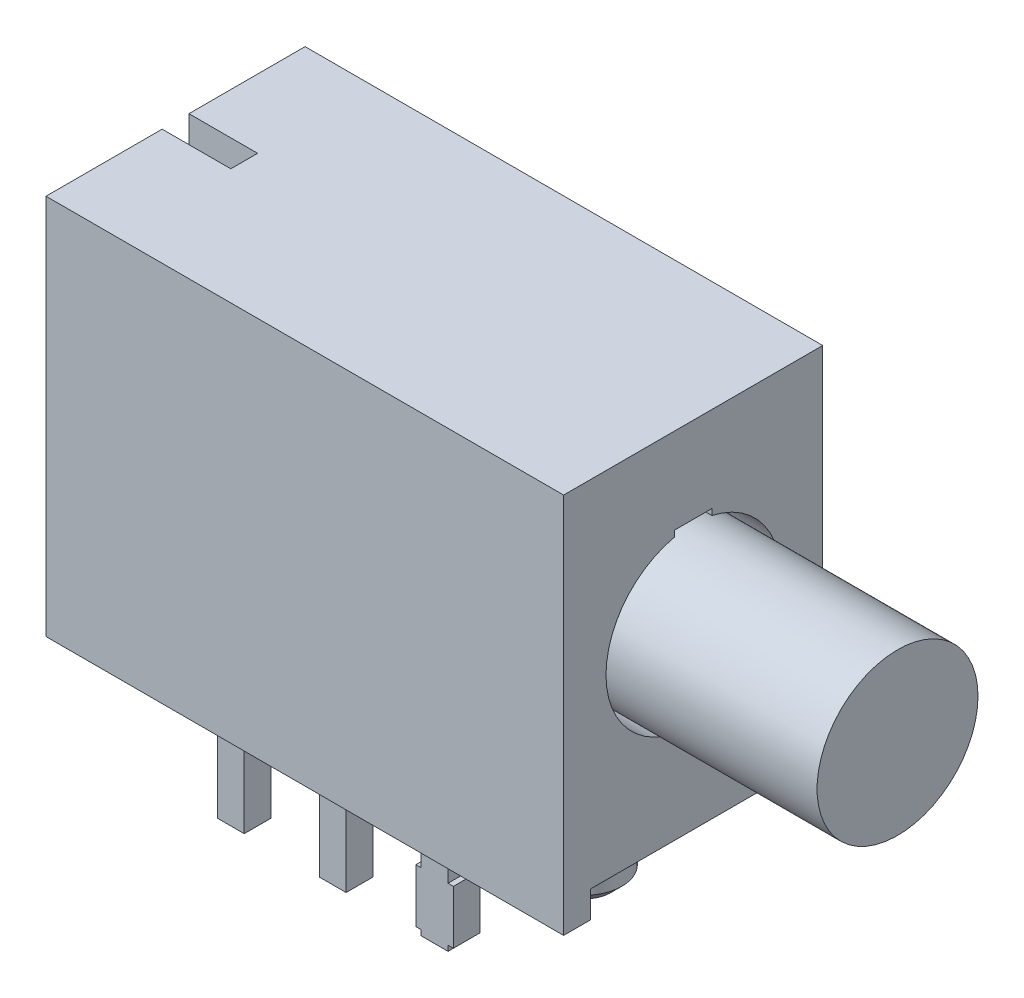
from build123d import *

# Parameters (mm, degrees)
SKETCH1_W          = 9.65
SKETCH1_H          = 7.11
EXTRUDE1_DEPTH     = 4.83
SKETCH3_W          = 3.83
SKETCH3_H          = 0.5
CUT_EXTRUDE1_DEPTH = 10.65
SKETCH3_3_R        = 1.5
EXTRUDE2_DEPTH     = 3.81
CUT_EXTRUDE2_DEPTH = 2.3
CUT_EXTRUDE3_DEPTH = 2.3
SKETCH4_W          = 0.5
SKETCH4_H          = 0.5
EXTRUDE3_DEPTH     = 4
SKETCH5_W          = 0.1
SKETCH5_H          = 1
SKETCH5_W_2        = 0.5
EXTRUDE4_DEPTH     = 0.5
SKETCH4_3_R        = 0.7
EXTRUDE5_DEPTH     = 1.78
CHAMFER1_SIZE      = 0.2
SKETCH3_8_R        = 1.625
SKETCH3_8_R_2      = 1.5
CUT_EXTRUDE4_DEPTH = 2.3
SKETCH7_W          = 1.4
SKETCH7_H          = 0.5
CUT_EXTRUDE5_DEPTH = 3.31
SKETCH7_5_W        = 1.3
SKETCH7_5_H        = 0.5
CUT_EXTRUDE6_DEPTH = 2.5
SKETCH8_W          = 1.03
SKETCH8_H          = 0.5
CUT_EXTRUDE7_DEPTH = 11.61
SKETCH8_5_W        = 0.25
SKETCH8_5_H        = 0.5
CUT_EXTRUDE8_DEPTH = 0.25
SKETCH9_W          = 0.026582278
SKETCH9_H          = 0.025316455
SKETCH9_H_2        = 0.025316456
CUT_EXTRUDE9_DEPTH = 0.01


with BuildPart() as part:
    # Sketch1 → Extrude1 (new body)
    with BuildSketch(Plane.XY):
        with Locations((4.825, 3.555)):
            Rectangle(SKETCH1_W, SKETCH1_H)
    extrude(amount=-EXTRUDE1_DEPTH)

    # Sketch3 → Cut-Extrude1 (cut, through all)
    with BuildSketch(Plane(origin=(9.65, 0, 0), x_dir=(0, 0, -1), z_dir=(1, 0, 0))):
        with Locations((2.415, 0.25)):
            Rectangle(SKETCH3_W, SKETCH3_H)
    extrude(amount=-CUT_EXTRUDE1_DEPTH, mode=Mode.SUBTRACT)

    # Sketch3_3 → Extrude2 (add)
    with BuildSketch(Plane(origin=(9.65, 0, 0), x_dir=(0, 0, -1), z_dir=(1, 0, 0))):
        with Locations((2.415, 3.81)):
            Circle(SKETCH3_3_R)
    extrude(amount=EXTRUDE2_DEPTH)

    # Sketch3_6 → Cut-Extrude2 (cut)
    with BuildSketch(Plane(origin=(9.65, 0, 0), x_dir=(0, 0, -1), z_dir=(1, 0, 0))):
        with BuildLine():
            Line((2.764999871, 5.51), (2.064999871, 5.51))
            Line((2.064999871, 5.51), (2.064999871, 5.396860079))
            ThreePointArc((2.064999871, 5.396860079), (2.414999868, 5.435), (2.764999871, 5.396860136))
            Line((2.764999871, 5.396860136), (2.764999871, 5.51))
        make_face()
    extrude(amount=-CUT_EXTRUDE2_DEPTH, mode=Mode.SUBTRACT)

    # Sketch3_7 → Cut-Extrude3 (cut)
    with BuildSketch(Plane(origin=(9.65, 0, 0), x_dir=(0, 0, -1), z_dir=(1, 0, 0))):
        with BuildLine():
            ThreePointArc((2.764999871, 2.223139864), (2.414999868, 2.185), (2.064999871, 2.223139921))
            Line((2.064999871, 2.223139921), (2.064999871, 2.11))
            Line((2.064999871, 2.11), (2.764999871, 2.11))
            Line((2.764999871, 2.11), (2.764999871, 2.223139864))
        make_face()
    extrude(amount=-CUT_EXTRUDE3_DEPTH, mode=Mode.SUBTRACT)

    # Sketch4 → Extrude3 (add)
    with BuildSketch(Plane.XZ.offset(-0.5)):
        with Locations((3.18, -2.415)):
            Rectangle(SKETCH4_W, SKETCH4_H)
        with Locations((5.08, -2.415)):
            Rectangle(SKETCH4_W, SKETCH4_H)
        with Locations((1.28, -2.415)):
            Rectangle(SKETCH4_W, SKETCH4_H)
    extrude(amount=EXTRUDE3_DEPTH)

    # Sketch5 → Extrude4 (add)
    with BuildSketch(Plane.XY.offset(-2.165)):
        with Locations((5.38, -2.9)):
            Rectangle(SKETCH5_W, SKETCH5_H)
        with Locations((5.08, -2.9)):
            Rectangle(SKETCH5_W_2, SKETCH5_H)
        with Locations((4.78, -2.9)):
            Rectangle(SKETCH5_W, SKETCH5_H)
    extrude(amount=-EXTRUDE4_DEPTH)

    # Sketch4_3 → Extrude5 (add)
    with BuildSketch(Plane.XZ.offset(-0.5)):
        with Locations(Location((7.62, -2.415, 0), (0, 0, 270))):  # turned: the seam where the file's is
            Circle(SKETCH4_3_R)
    extrude(amount=EXTRUDE5_DEPTH)

    # Chamfer1
    chamfer1_edges = [part.edges().sort_by_distance(p)[0] for p in [
        (7.62, -1.28, -1.715),
    ]]
    chamfer(chamfer1_edges, length=CHAMFER1_SIZE)

    # Sketch3_8 → Cut-Extrude4 (cut)
    with BuildSketch(Plane(origin=(9.65, 0, 0), x_dir=(0, 0, -1), z_dir=(1, 0, 0))):
        with Locations((2.415, 3.81)):
            Circle(SKETCH3_8_R)
        with Locations((2.415, 3.81)):
            Circle(SKETCH3_8_R_2, mode=Mode.SUBTRACT)
    extrude(amount=-CUT_EXTRUDE4_DEPTH, mode=Mode.SUBTRACT)

    # Sketch7 → Cut-Extrude5 (cut)
    with BuildSketch(Plane.XZ.offset(-0.5)):
        with Locations((2.23, -2.415)):
            Rectangle(SKETCH7_W, SKETCH7_H)
    extrude(amount=-CUT_EXTRUDE5_DEPTH, mode=Mode.SUBTRACT)

    # Sketch7_5 → Cut-Extrude6 (cut)
    with BuildSketch(Plane.XZ.offset(-0.5)):
        with Locations((4.08, -2.415)):
            Rectangle(SKETCH7_5_W, SKETCH7_5_H)
    extrude(amount=-CUT_EXTRUDE6_DEPTH, mode=Mode.SUBTRACT)

    # Sketch8 → Cut-Extrude7 (cut, through all)
    with BuildSketch(Plane(origin=(0, 7.11, 0), x_dir=(-1, 0, 0), z_dir=(0, 1, 0))):
        with Locations((-0.515, -2.415)):
            Rectangle(SKETCH8_W, SKETCH8_H)
    extrude(amount=-CUT_EXTRUDE7_DEPTH, mode=Mode.SUBTRACT)

    # Sketch8_5 → Cut-Extrude8 (cut)
    with BuildSketch(Plane(origin=(0, 7.11, 0), x_dir=(-1, 0, 0), z_dir=(0, 1, 0))):
        with Locations((-1.155, -2.415)):
            Rectangle(SKETCH8_5_W, SKETCH8_5_H)
    extrude(amount=-CUT_EXTRUDE8_DEPTH, mode=Mode.SUBTRACT)

    # Sketch9 → Cut-Extrude9 (cut)
    with BuildSketch(Plane.XZ.offset(-0.5)):
        Polygon((5.37653482, -1.857436776), (5.301851276, -1.833979497), (5.301851276, -1.809236618), (5.35218751, -1.792820478), (5.301851276, -1.777294371), (5.301851276, -1.751562567), (5.37653482, -1.728322852), (5.37653482, -1.753500858), (5.325051434, -1.76649532), (5.37653482, -1.782911459), (5.37653482, -1.804410668), (5.325051434, -1.820727915), (5.37653482, -1.833544371), align=None)
        Polygon((5.37653482, -1.991613991), (5.301851276, -1.968156713), (5.301851276, -1.943413833), (5.35218751, -1.926997694), (5.301851276, -1.911471586), (5.301851276, -1.885739782), (5.37653482, -1.862500067), (5.37653482, -1.887678073), (5.325051434, -1.900672535), (5.37653482, -1.917088675), (5.37653482, -1.938587883), (5.325051434, -1.95490513), (5.37653482, -1.967721586), align=None)
        Polygon((5.37653482, -2.125791206), (5.301851276, -2.102333928), (5.301851276, -2.077591048), (5.35218751, -2.061174909), (5.301851276, -2.045648801), (5.301851276, -2.019916997), (5.37653482, -1.996677282), (5.37653482, -2.021855288), (5.325051434, -2.03484975), (5.37653482, -2.05126589), (5.37653482, -2.072765099), (5.325051434, -2.089082345), (5.37653482, -2.101898801), align=None)
        with Locations((5.315142415, -2.153639307)):
            Rectangle(SKETCH9_W, SKETCH9_H)
        with BuildLine():
            add(Edge.make_bspline(
                [(5.333022162, -2.270095004), (5.331800028, -2.270058505), (5.329400166, -2.269986835), (5.325892478, -2.269377249), (5.322568174, -2.268383281), (5.319404028, -2.267010942), (5.31643454, -2.265217486), (5.313631648, -2.263034215), (5.311027104, -2.260445332), (5.308590729, -2.257498528), (5.306408618, -2.254201585), (5.304502585, -2.250603871), (5.302907914, -2.246723844), (5.301568848, -2.242575633), (5.300580415, -2.238129086), (5.299856427, -2.233411588), (5.29938311, -2.22841816), (5.299341142, -2.224994583), (5.29931963, -2.223239782)],
                knots=[0, 0, 0, 0, 0.907312236, 1.78165839, 2.635367075, 3.479697475, 4.336364812, 5.205276731, 6.11257575, 7.058770404, 8.040786331, 9.044147278, 10.078219212, 11.153049307, 12.278104542, 13.457648573, 14.696882856, 16, 16, 16, 16], degree=3))
            add(Edge.make_bspline(
                [(5.29931963, -2.223239782), (5.299343702, -2.221221527), (5.299390327, -2.217312344), (5.299818926, -2.211648819), (5.300465065, -2.206380782), (5.301431607, -2.201485067), (5.302632372, -2.196880468), (5.303923664, -2.1924472), (5.305388079, -2.188165889), (5.306488237, -2.185392799), (5.307033238, -2.184019054)],
                knots=[0, 0, 0, 0, 1.203215828, 2.33052265, 3.384689099, 4.366106119, 5.303329643, 6.221311756, 7.118865988, 8, 8, 8, 8], degree=3))
            Line((5.307033238, -2.184019054), (5.3309652, -2.184019054))
            Line((5.3309652, -2.184019054), (5.3309652, -2.186867156))
            add(Edge.make_bspline(
                [(5.3309652, -2.186867156), (5.329883745, -2.18823247), (5.327727184, -2.190955082), (5.324964579, -2.195388315), (5.322562416, -2.200035961), (5.320588414, -2.204881432), (5.31900209, -2.209778276), (5.317908563, -2.214653654), (5.317161214, -2.219419242), (5.317080707, -2.222577811), (5.317041149, -2.224129814)],
                knots=[0, 0, 0, 0, 1.030622468, 2.055194264, 3.087043286, 4.125157485, 5.149848264, 6.130935704, 7.081611712, 8, 8, 8, 8], degree=3))
            add(Edge.make_bspline(
                [(5.317041149, -2.224129814), (5.317042044, -2.224558592), (5.317043959, -2.225476574), (5.317172802, -2.226944611), (5.317265965, -2.22860321), (5.317475183, -2.230382077), (5.317693766, -2.232172894), (5.318074086, -2.233827554), (5.318435925, -2.235331193), (5.318804103, -2.236237675), (5.318979441, -2.236669371)],
                knots=[0, 0, 0, 0, 0.806378557, 1.726393851, 2.771014456, 3.931269413, 5.096090628, 6.161710732, 7.124547685, 8, 8, 8, 8], degree=3))
            add(Edge.make_bspline(
                [(5.318979441, -2.236669371), (5.319207264, -2.237149158), (5.319654986, -2.238092041), (5.320472593, -2.23938696), (5.321343895, -2.240569633), (5.322309314, -2.241631093), (5.323487223, -2.24248136), (5.324888079, -2.243109561), (5.326538379, -2.243452655), (5.32771339, -2.243491949), (5.328334662, -2.243512725)],
                knots=[0, 0, 0, 0, 1.024407818, 2.013179384, 2.949802342, 3.859052226, 4.77034807, 5.732977883, 6.801339628, 8, 8, 8, 8], degree=3))
            add(Edge.make_bspline(
                [(5.328334662, -2.243512725), (5.328880558, -2.243481283), (5.329953951, -2.24341946), (5.331481947, -2.242837668), (5.332903824, -2.24195477), (5.334164539, -2.240667748), (5.335321977, -2.239073671), (5.336292274, -2.237117934), (5.337172348, -2.234864955), (5.337589617, -2.233220496), (5.337808554, -2.232357662)],
                knots=[0, 0, 0, 0, 0.825212765, 1.622611382, 2.449701629, 3.348069183, 4.336544339, 5.428209675, 6.6506027, 8, 8, 8, 8], degree=3))
            add(Edge.make_bspline(
                [(5.337808554, -2.232357662), (5.338256295, -2.230388935), (5.339173485, -2.226356027), (5.340320592, -2.220207918), (5.341586665, -2.21407769), (5.342796206, -2.210118979), (5.343386086, -2.208188358)],
                knots=[0, 0, 0, 0, 0.976104583, 1.999535498, 3.024395274, 4, 4, 4, 4], degree=3))
            add(Edge.make_bspline(
                [(5.343386086, -2.208188358), (5.343739079, -2.207149842), (5.344426212, -2.205128274), (5.345587837, -2.20223673), (5.346857789, -2.199575617), (5.34821292, -2.197135507), (5.349686918, -2.194936185), (5.351220308, -2.192940995), (5.352874145, -2.191197469), (5.354606065, -2.189649785), (5.356458067, -2.188326471), (5.358402204, -2.187171721), (5.360462669, -2.186196085), (5.362623958, -2.185387202), (5.364902826, -2.184770129), (5.3672797, -2.184348873), (5.36976306, -2.184050484), (5.371457413, -2.184029674), (5.372322004, -2.184019054)],
                knots=[0, 0, 0, 0, 1.287286806, 2.505824366, 3.654938963, 4.74627059, 5.778586806, 6.75996495, 7.696030012, 8.595059759, 9.482019644, 10.363222407, 11.245851011, 12.154256429, 13.068444161, 14.012503255, 14.985824751, 16, 16, 16, 16], degree=3))
            add(Edge.make_bspline(
                [(5.372322004, -2.184019054), (5.373478149, -2.184056356), (5.375753421, -2.184129766), (5.379082465, -2.184731194), (5.382231202, -2.185757784), (5.385234665, -2.187143848), (5.388047751, -2.188972476), (5.390726298, -2.19115727), (5.39319789, -2.193781318), (5.395498223, -2.196758439), (5.397577622, -2.200045824), (5.399408178, -2.203584807), (5.40094483, -2.207354096), (5.402218724, -2.211339643), (5.403173395, -2.215558112), (5.403892326, -2.219995345), (5.404305508, -2.224669133), (5.404356758, -2.227860555), (5.404382922, -2.229489782)],
                knots=[0, 0, 0, 0, 0.894990994, 1.761326291, 2.609044902, 3.454222546, 4.315366365, 5.200560057, 6.125081389, 7.100429509, 8.110379559, 9.133447974, 10.182136699, 11.259192205, 12.370181258, 13.528580438, 14.738335141, 16, 16, 16, 16], degree=3))
            add(Edge.make_bspline(
                [(5.404382922, -2.229489782), (5.40436073, -2.231158469), (5.404316385, -2.234493014), (5.403938407, -2.239474456), (5.403383179, -2.244434958), (5.402541473, -2.249298789), (5.401565056, -2.253989344), (5.400469261, -2.25840258), (5.399231296, -2.26248204), (5.398276951, -2.265055704), (5.397816466, -2.266297535)],
                knots=[0, 0, 0, 0, 1.065403572, 2.129000689, 3.188532477, 4.251604565, 5.279552602, 6.247508681, 7.154397237, 8, 8, 8, 8], degree=3))
            Line((5.397816466, -2.266297535), (5.375268998, -2.266297535))
            Line((5.375268998, -2.266297535), (5.375268998, -2.263469213))
            add(Edge.make_bspline(
                [(5.375268998, -2.263469213), (5.376069344, -2.262396308), (5.377706074, -2.260202189), (5.379789746, -2.256542553), (5.381747612, -2.252584317), (5.383431771, -2.248305486), (5.384891252, -2.243846459), (5.385910418, -2.2392635), (5.386552228, -2.234637337), (5.386625003, -2.231535626), (5.386661403, -2.229984244)],
                knots=[0, 0, 0, 0, 0.892283326, 1.824742884, 2.804416662, 3.836872171, 4.8899239, 5.931447339, 6.965372909, 8, 8, 8, 8], degree=3))
            add(Edge.make_bspline(
                [(5.386661403, -2.229984244), (5.38663995, -2.228888576), (5.386597048, -2.22669736), (5.386206364, -2.223429151), (5.38557547, -2.220187091), (5.384756188, -2.218146568), (5.38434732, -2.217128231)],
                knots=[0, 0, 0, 0, 0.999146175, 1.998183711, 3.000980573, 4, 4, 4, 4], degree=3))
            add(Edge.make_bspline(
                [(5.38434732, -2.217128231), (5.384145853, -2.216694728), (5.383743054, -2.215828011), (5.38297049, -2.214621366), (5.382041679, -2.213516697), (5.380989687, -2.21252462), (5.379833314, -2.211656222), (5.378558488, -2.211040871), (5.377195573, -2.210664998), (5.376260342, -2.21062284), (5.375783238, -2.210601333)],
                knots=[0, 0, 0, 0, 1.00524851, 2.009826503, 3.004679593, 4.035271301, 5.048246368, 6.034938417, 6.997532266, 8, 8, 8, 8], degree=3))
            add(Edge.make_bspline(
                [(5.375783238, -2.210601333), (5.375145073, -2.210635771), (5.373925597, -2.210701579), (5.372209801, -2.211308163), (5.370731367, -2.212292997), (5.369736447, -2.213453602), (5.369039009, -2.214570731), (5.368528499, -2.215606391), (5.36804514, -2.216815618), (5.367547671, -2.218186865), (5.367056484, -2.219723193), (5.366580937, -2.22143175), (5.366131641, -2.223314467), (5.365845451, -2.224630341), (5.365696213, -2.225316523)],
                knots=[0, 0, 0, 0, 1.173816843, 2.243057204, 3.312297565, 4.415174738, 5.03266065, 5.73970059, 6.541434878, 7.433956553, 8.430083051, 9.515931566, 10.70464786, 12, 12, 12, 12], degree=3))
            add(Edge.make_bspline(
                [(5.365696213, -2.225316523), (5.365320151, -2.227149312), (5.364581273, -2.230750338), (5.363477785, -2.236151522), (5.362202816, -2.241654295), (5.361054013, -2.245319622), (5.360454915, -2.24723108)],
                knots=[0, 0, 0, 0, 0.995744513, 1.956417928, 2.934277412, 4, 4, 4, 4], degree=3))
            add(Edge.make_bspline(
                [(5.360454915, -2.24723108), (5.360135671, -2.248177634), (5.359511179, -2.250029247), (5.358424896, -2.252669877), (5.357250913, -2.255116936), (5.356009382, -2.257383969), (5.354665416, -2.259457939), (5.353242769, -2.261352621), (5.35171586, -2.26303644), (5.350102632, -2.264534005), (5.348392532, -2.265853165), (5.346553459, -2.266985463), (5.344604657, -2.267957691), (5.342518457, -2.268727296), (5.34032387, -2.269345316), (5.337992502, -2.269768413), (5.335548126, -2.270062397), (5.333873548, -2.270084013), (5.333022162, -2.270095004)],
                knots=[0, 0, 0, 0, 1.237467875, 2.420686895, 3.535046182, 4.599015201, 5.620884487, 6.594603852, 7.531477383, 8.433220087, 9.318759595, 10.202828513, 11.105163009, 12.01247538, 12.953896178, 13.926381251, 14.945733412, 16, 16, 16, 16], degree=3))
        make_face()
        with BuildLine():
            Line((5.301851276, -2.362500067), (5.301851276, -2.338449434))
            Line((5.301851276, -2.338449434), (5.309683554, -2.338449434))
            add(Edge.make_bspline(
                [(5.309683554, -2.338449434), (5.308874996, -2.337356125), (5.307316107, -2.335248242), (5.30523589, -2.332075217), (5.303460624, -2.329049126), (5.301901403, -2.326135636), (5.300726018, -2.323113432), (5.299897952, -2.319881918), (5.299398179, -2.316379094), (5.299346395, -2.313952199), (5.29931963, -2.312697852)],
                knots=[0, 0, 0, 0, 1.150872466, 2.218865267, 3.209461834, 4.120482262, 5.012764827, 5.946708227, 6.938749913, 8, 8, 8, 8], degree=3))
            add(Edge.make_bspline(
                [(5.29931963, -2.312697852), (5.299342349, -2.3116815), (5.29938659, -2.309702369), (5.299731468, -2.306825129), (5.300269119, -2.304117501), (5.30107671, -2.301602462), (5.302042513, -2.299238472), (5.303322471, -2.297100923), (5.304752645, -2.295097321), (5.306459691, -2.293315648), (5.308357424, -2.291700027), (5.310489884, -2.290317477), (5.31282281, -2.289139766), (5.315374664, -2.288198668), (5.318132967, -2.287443579), (5.321112215, -2.286919647), (5.324299342, -2.286599054), (5.326494472, -2.286567115), (5.327622637, -2.2865507)],
                knots=[0, 0, 0, 0, 1.109008058, 2.159558935, 3.158726032, 4.116861086, 5.039058877, 5.938775559, 6.82970133, 7.720510853, 8.624361809, 9.544451588, 10.487360536, 11.471068125, 12.508000841, 13.604731202, 14.768976642, 16, 16, 16, 16], degree=3))
            Line((5.327622637, -2.2865507), (5.37653482, -2.2865507))
            Line((5.37653482, -2.2865507), (5.37653482, -2.310601333))
            Line((5.37653482, -2.310601333), (5.338955706, -2.310601333))
            add(Edge.make_bspline(
                [(5.338955706, -2.310601333), (5.338039235, -2.310602968), (5.33628502, -2.310606099), (5.333779213, -2.310688438), (5.331511041, -2.310809338), (5.329469012, -2.310948043), (5.327622261, -2.31120106), (5.3259561, -2.311578768), (5.324436498, -2.312049594), (5.323529797, -2.312513913), (5.323093365, -2.312737409)],
                knots=[0, 0, 0, 0, 1.361401701, 2.605856924, 3.723918663, 4.735739235, 5.645738665, 6.489217889, 7.27279937, 8, 8, 8, 8], degree=3))
            add(Edge.make_bspline(
                [(5.323093365, -2.312737409), (5.32269465, -2.312967415), (5.32191081, -2.313419589), (5.320904632, -2.314339879), (5.320060365, -2.315418622), (5.319404336, -2.316696225), (5.318905387, -2.318182773), (5.318565151, -2.319910704), (5.318349649, -2.321896066), (5.318321741, -2.323305084), (5.318306972, -2.3240507)],
                knots=[0, 0, 0, 0, 0.849138082, 1.669332372, 2.503455908, 3.370611167, 4.311442699, 5.394692208, 6.621337967, 8, 8, 8, 8], degree=3))
            add(Edge.make_bspline(
                [(5.318306972, -2.3240507), (5.318324329, -2.324591984), (5.318360017, -2.325704901), (5.318592462, -2.327416214), (5.318949137, -2.329212791), (5.319608993, -2.331727374), (5.320795172, -2.334894001), (5.322149579, -2.337253302), (5.322836244, -2.338449434)],
                knots=[0, 0, 0, 0, 0.638127216, 1.312033637, 2.033062677, 2.79661882, 4.375931797, 6, 6, 6, 6], degree=3))
            Line((5.322836244, -2.338449434), (5.37653482, -2.338449434))
            Line((5.37653482, -2.338449434), (5.37653482, -2.362500067))
            Line((5.37653482, -2.362500067), (5.301851276, -2.362500067))
        make_face()
        with BuildLine():
            Line((5.301851276, -2.459968421), (5.301851276, -2.435917788))
            Line((5.301851276, -2.435917788), (5.33943039, -2.435917788))
            add(Edge.make_bspline(
                [(5.33943039, -2.435917788), (5.340960433, -2.435893274), (5.344011458, -2.43584439), (5.347773868, -2.435562267), (5.350616193, -2.435183745), (5.352454074, -2.434814089), (5.354002213, -2.434382389), (5.354887973, -2.433970109), (5.355292732, -2.433781713)],
                knots=[0, 0, 0, 0, 1.709124929, 3.408128882, 4.211124727, 4.91016634, 5.501986363, 6, 6, 6, 6], degree=3))
            add(Edge.make_bspline(
                [(5.355292732, -2.433781713), (5.355690785, -2.43353725), (5.356471225, -2.433057946), (5.357484238, -2.432120622), (5.358313079, -2.431026736), (5.358994629, -2.429755966), (5.35946521, -2.42826477), (5.35985844, -2.426548029), (5.360025349, -2.424561411), (5.360060509, -2.423154141), (5.360079124, -2.422409086)],
                knots=[0, 0, 0, 0, 0.86006424, 1.686277094, 2.52783008, 3.38194165, 4.331801563, 5.402842185, 6.624978739, 8, 8, 8, 8], degree=3))
            add(Edge.make_bspline(
                [(5.360079124, -2.422409086), (5.360022387, -2.421277264), (5.359906533, -2.41896617), (5.359195026, -2.416103976), (5.358376067, -2.413773372), (5.357617236, -2.411920848), (5.356645794, -2.410012217), (5.355923972, -2.408732805), (5.355549852, -2.408069687)],
                knots=[0, 0, 0, 0, 1.338371478, 2.732853438, 3.468019217, 4.261884641, 5.099136535, 6, 6, 6, 6], degree=3))
            Line((5.355549852, -2.408069687), (5.301851276, -2.408069687))
            Line((5.301851276, -2.408069687), (5.301851276, -2.384019054))
            Line((5.301851276, -2.384019054), (5.37653482, -2.384019054))
            Line((5.37653482, -2.384019054), (5.37653482, -2.408069687))
            Line((5.37653482, -2.408069687), (5.368702542, -2.408069687))
            add(Edge.make_bspline(
                [(5.368702542, -2.408069687), (5.369508693, -2.409127094), (5.371077916, -2.411185398), (5.373118336, -2.414364636), (5.374917105, -2.417448534), (5.376429922, -2.420501544), (5.377636697, -2.423616499), (5.378447686, -2.426879257), (5.378991489, -2.430295663), (5.379041182, -2.432632379), (5.379066466, -2.433821269)],
                knots=[0, 0, 0, 0, 1.126119141, 2.192057864, 3.198061997, 4.149848529, 5.076251285, 6.021887753, 6.99356175, 8, 8, 8, 8], degree=3))
            add(Edge.make_bspline(
                [(5.379066466, -2.433821269), (5.379041077, -2.434817541), (5.378991513, -2.43676244), (5.378681803, -2.439597201), (5.378131139, -2.442268621), (5.377333309, -2.444760895), (5.376347698, -2.447103515), (5.375116183, -2.44926546), (5.37365776, -2.45125753), (5.371996757, -2.453085931), (5.370107031, -2.454716749), (5.367989766, -2.456133785), (5.36564667, -2.457313767), (5.363086361, -2.458284479), (5.360321252, -2.459058902), (5.357325286, -2.459574033), (5.354121107, -2.459927817), (5.351905064, -2.459954616), (5.35076346, -2.459968421)],
                knots=[0, 0, 0, 0, 1.08848837, 2.124922927, 3.110950502, 4.063144162, 4.979605775, 5.882838355, 6.774625441, 7.671951181, 8.57587277, 9.494821853, 10.448322275, 11.435533005, 12.482327682, 13.580118324, 14.753386918, 16, 16, 16, 16], degree=3))
            Line((5.35076346, -2.459968421), (5.301851276, -2.459968421))
        make_face()
        Polygon((5.301851276, -2.55490513), (5.301851276, -2.482753231), (5.401851276, -2.482753231), (5.401851276, -2.508069687), (5.320838618, -2.508069687), (5.320838618, -2.55490513), align=None)
        Polygon((5.301851276, -2.642246902), (5.301851276, -2.570095004), (5.401851276, -2.570095004), (5.401851276, -2.642246902), (5.382863934, -2.642246902), (5.382863934, -2.595411459), (5.365142415, -2.595411459), (5.365142415, -2.638449434), (5.346155073, -2.638449434), (5.346155073, -2.595411459), (5.320838618, -2.595411459), (5.320838618, -2.642246902), align=None)
        with BuildLine():
            add(Edge.make_bspline(
                [(5.351752384, -2.758702599), (5.350604695, -2.758683283), (5.348331809, -2.758645031), (5.344967002, -2.75834984), (5.341701327, -2.757823814), (5.338517078, -2.757144633), (5.33543815, -2.756222127), (5.332430573, -2.755140414), (5.32952508, -2.753830768), (5.326723645, -2.752325915), (5.324051542, -2.750676443), (5.321531334, -2.748901694), (5.319148116, -2.747055915), (5.316953222, -2.745066602), (5.314911202, -2.74298742), (5.313020388, -2.740811892), (5.311316957, -2.738506827), (5.310294073, -2.736899665), (5.309782447, -2.736095795)],
                knots=[0, 0, 0, 0, 1.105570398, 2.18947457, 3.250358341, 4.290584537, 5.323553275, 6.344225964, 7.367641686, 8.3905646, 9.405808457, 10.390761353, 11.358902336, 12.307789878, 13.241960776, 14.165076779, 15.082208636, 16, 16, 16, 16], degree=3))
            add(Edge.make_bspline(
                [(5.309782447, -2.736095795), (5.309070308, -2.734856567), (5.307642395, -2.732371787), (5.305973804, -2.728387952), (5.304569688, -2.72426247), (5.303515264, -2.719912084), (5.30278822, -2.715265074), (5.302227414, -2.710263665), (5.301925654, -2.704856075), (5.301876634, -2.701121181), (5.301851276, -2.699189149)],
                knots=[0, 0, 0, 0, 0.896288622, 1.797150563, 2.705281913, 3.629615989, 4.602417572, 5.655716007, 6.787320449, 8, 8, 8, 8], degree=3))
            Line((5.301851276, -2.699189149), (5.301851276, -2.66376589))
            Line((5.301851276, -2.66376589), (5.401851276, -2.66376589))
            Line((5.401851276, -2.66376589), (5.401851276, -2.700197852))
            add(Edge.make_bspline(
                [(5.401851276, -2.700197852), (5.401834665, -2.702176584), (5.401802624, -2.705993312), (5.401385034, -2.711510151), (5.40078821, -2.716615359), (5.399863339, -2.721300707), (5.398747994, -2.725600712), (5.397388865, -2.729526187), (5.395890158, -2.733137961), (5.394616465, -2.735316803), (5.393999219, -2.736372694)],
                knots=[0, 0, 0, 0, 1.267175336, 2.444223962, 3.542125549, 4.557526608, 5.500936977, 6.385043188, 7.217374394, 8, 8, 8, 8], degree=3))
            add(Edge.make_bspline(
                [(5.393999219, -2.736372694), (5.393462678, -2.737223647), (5.392395765, -2.738915771), (5.390613913, -2.741316986), (5.388657836, -2.743546413), (5.386606017, -2.745674916), (5.38440313, -2.747654734), (5.382064423, -2.749497933), (5.379586329, -2.751201751), (5.37697686, -2.752759714), (5.374246808, -2.754180529), (5.371373749, -2.755369835), (5.368395219, -2.756419184), (5.365286257, -2.75722472), (5.36207842, -2.757922634), (5.358737076, -2.758357369), (5.355284588, -2.75864398), (5.352939698, -2.758682894), (5.351752384, -2.758702599)],
                knots=[0, 0, 0, 0, 0.964065863, 1.917049184, 2.86229036, 3.805247319, 4.749389377, 5.698846072, 6.657678277, 7.629829384, 8.610569287, 9.604676042, 10.607940105, 11.6349849, 12.681042988, 13.752616828, 14.862056989, 16, 16, 16, 16], degree=3))
        make_face()
        with BuildLine():
            add(Edge.make_bspline(
                [(5.351910611, -2.73212032), (5.352715371, -2.732110079), (5.354293955, -2.732089992), (5.35660947, -2.731898424), (5.35883912, -2.731639368), (5.360973812, -2.731208314), (5.363033383, -2.730708667), (5.364990877, -2.730066518), (5.36687045, -2.729342121), (5.368647939, -2.728460483), (5.370356321, -2.727486846), (5.371941836, -2.726339353), (5.373454723, -2.725091016), (5.374882707, -2.723712729), (5.376188603, -2.722169789), (5.377418679, -2.720509686), (5.378547005, -2.718709328), (5.379207055, -2.71743634), (5.379541149, -2.716791997)],
                knots=[0, 0, 0, 0, 1.152093354, 2.259898929, 3.325467225, 4.364140538, 5.376172865, 6.358396836, 7.312077728, 8.257828931, 9.196960457, 10.124297759, 11.056236784, 12.004246951, 12.961658638, 13.947279359, 14.960983522, 16, 16, 16, 16], degree=3))
            add(Edge.make_bspline(
                [(5.379541149, -2.716791997), (5.379847861, -2.7161171), (5.380455786, -2.714779405), (5.381186978, -2.712708583), (5.381759814, -2.710619199), (5.382190672, -2.7084176), (5.382512603, -2.70594784), (5.382709861, -2.703022258), (5.382852031, -2.699566349), (5.382859782, -2.697079634), (5.382863934, -2.695747694)],
                knots=[0, 0, 0, 0, 0.826967603, 1.639107464, 2.447640171, 3.242670507, 4.14065217, 5.225198036, 6.513753944, 8, 8, 8, 8], degree=3))
            Line((5.382863934, -2.695747694), (5.382863934, -2.689082345))
            Line((5.382863934, -2.689082345), (5.320838618, -2.689082345))
            Line((5.320838618, -2.689082345), (5.320838618, -2.695747694))
            add(Edge.make_bspline(
                [(5.320838618, -2.695747694), (5.320843367, -2.6965059), (5.320852537, -2.697969666), (5.320895599, -2.700085909), (5.320942487, -2.702051706), (5.321058949, -2.703856577), (5.321131595, -2.705515261), (5.321309974, -2.707002042), (5.321452154, -2.708344532), (5.321719877, -2.709912128), (5.32213606, -2.711765294), (5.322814239, -2.713926555), (5.323664634, -2.716067089), (5.324349601, -2.717455662), (5.324695422, -2.718156713)],
                knots=[0, 0, 0, 0, 1.186793418, 2.291178421, 3.313283093, 4.264083014, 5.122158624, 5.910777728, 6.607099052, 7.234812932, 8.398911528, 9.577194775, 10.776795607, 12, 12, 12, 12], degree=3))
            add(Edge.make_bspline(
                [(5.324695422, -2.718156713), (5.325036938, -2.718741828), (5.325710452, -2.719895754), (5.326844526, -2.721519259), (5.328052251, -2.723026977), (5.329340702, -2.724422989), (5.330728943, -2.725686288), (5.332195485, -2.726838307), (5.333743463, -2.727868756), (5.335936981, -2.729104145), (5.338967918, -2.730327391), (5.342935304, -2.731366934), (5.347295067, -2.732003805), (5.350332685, -2.732080487), (5.351910611, -2.73212032)],
                knots=[0, 0, 0, 0, 0.755160452, 1.489275589, 2.205657296, 2.907868421, 3.605098304, 4.296256403, 4.985378686, 5.676536785, 7.100390329, 8.614249252, 10.241231541, 12, 12, 12, 12], degree=3))
        make_face(mode=Mode.SUBTRACT)
        with Locations((5.315142415, -2.790348168)):
            Rectangle(SKETCH9_W, SKETCH9_H_2)
        with BuildLine():
            add(Edge.make_bspline(
                [(5.29931963, -2.864992156), (5.299341442, -2.863402043), (5.299384253, -2.860280906), (5.29986117, -2.855709565), (5.300578866, -2.851344392), (5.301599772, -2.847198084), (5.302947268, -2.843284293), (5.304600204, -2.839620655), (5.306585388, -2.836213798), (5.308164597, -2.834155151), (5.308951751, -2.833129023)],
                knots=[0, 0, 0, 0, 1.123670284, 2.205584497, 3.245308791, 4.249063313, 5.220352711, 6.167273909, 7.086481357, 8, 8, 8, 8], degree=3))
            add(Edge.make_bspline(
                [(5.308951751, -2.833129023), (5.309806525, -2.832177275), (5.311512768, -2.83027746), (5.314484195, -2.827811527), (5.317767239, -2.825688442), (5.321369461, -2.823902889), (5.32528619, -2.822471966), (5.329530852, -2.821448832), (5.334091633, -2.820829586), (5.337239566, -2.820762421), (5.338856814, -2.820727915)],
                knots=[0, 0, 0, 0, 0.916457077, 1.82937027, 2.759194969, 3.714948755, 4.706655623, 5.743329475, 6.840637961, 8, 8, 8, 8], degree=3))
            add(Edge.make_bspline(
                [(5.338856814, -2.820727915), (5.340560041, -2.820766675), (5.343861121, -2.820841798), (5.348633309, -2.821505558), (5.353050989, -2.82257517), (5.357102898, -2.824112728), (5.360796089, -2.82604317), (5.364167924, -2.828307663), (5.367210848, -2.830928189), (5.368956288, -2.832935327), (5.369829915, -2.83393994)],
                knots=[0, 0, 0, 0, 1.171797512, 2.271099083, 3.308930235, 4.294129479, 5.24602549, 6.17106565, 7.084581485, 8, 8, 8, 8], degree=3))
            add(Edge.make_bspline(
                [(5.369829915, -2.83393994), (5.370598502, -2.834965811), (5.372144958, -2.837029942), (5.374045657, -2.840433447), (5.375640443, -2.844056662), (5.376888088, -2.847886233), (5.377841993, -2.851859042), (5.378565837, -2.855918701), (5.378986395, -2.860064954), (5.379039647, -2.862855155), (5.379066466, -2.864260352)],
                knots=[0, 0, 0, 0, 0.952130878, 1.915761808, 2.890227217, 3.891541892, 4.905612075, 5.925811839, 6.955400088, 8, 8, 8, 8], degree=3))
            add(Edge.make_bspline(
                [(5.379066466, -2.864260352), (5.379049464, -2.86550707), (5.379016031, -2.867958542), (5.378693922, -2.871559589), (5.378160803, -2.87501413), (5.3774222, -2.878319062), (5.376530597, -2.881493008), (5.375491456, -2.884543185), (5.374358188, -2.887502996), (5.373473653, -2.889403564), (5.373034029, -2.890348168)],
                knots=[0, 0, 0, 0, 1.107648782, 2.178012834, 3.209595929, 4.211695017, 5.185427128, 6.137685403, 7.07440854, 8, 8, 8, 8], degree=3))
            Line((5.373034029, -2.890348168), (5.352484187, -2.890348168))
            Line((5.352484187, -2.890348168), (5.352484187, -2.887005605))
            add(Edge.make_bspline(
                [(5.352484187, -2.887005605), (5.352901407, -2.886506061), (5.353803122, -2.885426425), (5.355223874, -2.883640009), (5.356753467, -2.881491067), (5.357645413, -2.879837531), (5.358121054, -2.878955763)],
                knots=[0, 0, 0, 0, 0.792826818, 1.713491785, 2.780691913, 4, 4, 4, 4], degree=3))
            add(Edge.make_bspline(
                [(5.358121054, -2.878955763), (5.358563012, -2.878027828), (5.359468872, -2.876125883), (5.360301706, -2.873569878), (5.360869432, -2.871377877), (5.361125854, -2.86956034), (5.361315415, -2.86762672), (5.361334922, -2.866291478), (5.361344947, -2.865605288)],
                knots=[0, 0, 0, 0, 1.332524827, 2.731214173, 3.480270227, 4.267952375, 5.109889624, 6, 6, 6, 6], degree=3))
            add(Edge.make_bspline(
                [(5.361344947, -2.865605288), (5.361325397, -2.864839733), (5.361287511, -2.863356122), (5.361010455, -2.861194614), (5.360532197, -2.859176202), (5.359892097, -2.85727298), (5.359004484, -2.855534917), (5.357970847, -2.853908077), (5.356745045, -2.852415818), (5.355304103, -2.851096557), (5.353724174, -2.84990383), (5.351990059, -2.848884629), (5.35014346, -2.847972173), (5.348139011, -2.847277234), (5.346010235, -2.846717496), (5.343747115, -2.846328567), (5.341347605, -2.846086608), (5.339701297, -2.846058691), (5.338856814, -2.846044371)],
                knots=[0, 0, 0, 0, 1.087302107, 2.107140881, 3.088415001, 4.030197574, 4.951552271, 5.852940509, 6.764198256, 7.685219758, 8.621679636, 9.570836121, 10.538340132, 11.542450476, 12.578202196, 13.66207107, 14.800746211, 16, 16, 16, 16], degree=3))
            add(Edge.make_bspline(
                [(5.338856814, -2.846044371), (5.337992658, -2.846059145), (5.336313645, -2.846087851), (5.333872034, -2.846321365), (5.331590603, -2.846737257), (5.329465283, -2.847308504), (5.327499265, -2.848032853), (5.325701868, -2.84893797), (5.324045061, -2.849974326), (5.322582449, -2.851218884), (5.321266127, -2.852582768), (5.320129993, -2.854097659), (5.319181848, -2.855756899), (5.318377385, -2.857539079), (5.317798987, -2.85947212), (5.317362295, -2.861528656), (5.317073738, -2.863718212), (5.317052175, -2.865228566), (5.317041149, -2.866000858)],
                knots=[0, 0, 0, 0, 1.230336593, 2.390482092, 3.487897344, 4.52859895, 5.520747884, 6.465347575, 7.38981449, 8.296085817, 9.192433006, 10.084246191, 10.984321635, 11.908883871, 12.862027947, 13.850751296, 14.901019963, 16, 16, 16, 16], degree=3))
            add(Edge.make_bspline(
                [(5.317041149, -2.866000858), (5.317049277, -2.866726712), (5.317065121, -2.868141738), (5.317283198, -2.870206484), (5.317559081, -2.872167393), (5.317998489, -2.874002933), (5.318540863, -2.875698199), (5.31910737, -2.877258622), (5.319712154, -2.878671069), (5.320179709, -2.879532423), (5.320403491, -2.879944687)],
                knots=[0, 0, 0, 0, 1.200823684, 2.340960236, 3.433630075, 4.476504061, 5.46014544, 6.378484521, 7.223905657, 8, 8, 8, 8], degree=3))
            add(Edge.make_bspline(
                [(5.320403491, -2.879944687), (5.320833386, -2.880644893), (5.321665028, -2.88199946), (5.323066594, -2.883838188), (5.324480853, -2.885483057), (5.325437071, -2.886507568), (5.325901909, -2.887005605)],
                knots=[0, 0, 0, 0, 1.098601379, 2.125273733, 3.088655601, 4, 4, 4, 4], degree=3))
            Line((5.325901909, -2.887005605), (5.325901909, -2.890348168))
            Line((5.325901909, -2.890348168), (5.305193839, -2.890348168))
            add(Edge.make_bspline(
                [(5.305193839, -2.890348168), (5.304756345, -2.889402778), (5.303881252, -2.887511771), (5.30272738, -2.884597192), (5.301759219, -2.881609219), (5.300856139, -2.878560847), (5.300167777, -2.875388763), (5.299674654, -2.872065733), (5.299373742, -2.868584234), (5.299337913, -2.866205845), (5.29931963, -2.864992156)],
                knots=[0, 0, 0, 0, 0.952012952, 1.904254716, 2.862729541, 3.822037426, 4.808956931, 5.82647221, 6.890850784, 8, 8, 8, 8], degree=3))
        make_face()
        with BuildLine():
            add(Edge.make_bspline(
                [(5.339153491, -2.982753231), (5.337648585, -2.982728536), (5.334715119, -2.982680398), (5.330443328, -2.982141081), (5.32640733, -2.981328302), (5.322620122, -2.98015577), (5.319062847, -2.978675378), (5.315773055, -2.976824439), (5.312719825, -2.974653434), (5.30992994, -2.972162397), (5.30743143, -2.969361195), (5.305236177, -2.966287013), (5.303422735, -2.962913185), (5.301910645, -2.959298875), (5.30074141, -2.955414223), (5.299928692, -2.951260003), (5.299393222, -2.946842869), (5.29934457, -2.943804451), (5.29931963, -2.942246902)],
                knots=[0, 0, 0, 0, 1.120167703, 2.183507516, 3.201345984, 4.182878364, 5.131270247, 6.065524964, 6.98789854, 7.91635504, 8.84481154, 9.778033504, 10.722808862, 11.691211189, 12.691525459, 13.738229926, 14.840575679, 16, 16, 16, 16], degree=3))
            add(Edge.make_bspline(
                [(5.29931963, -2.942246902), (5.299344652, -2.940689381), (5.299393465, -2.937651016), (5.299927796, -2.933233506), (5.300745747, -2.929074411), (5.301901848, -2.925185104), (5.303428397, -2.921576358), (5.305235445, -2.918206492), (5.307431638, -2.915132726), (5.30992983, -2.912331241), (5.312720057, -2.909840922), (5.315772239, -2.907667331), (5.319068193, -2.905824917), (5.322611239, -2.904307064), (5.326412077, -2.903173739), (5.330442518, -2.902350277), (5.334715338, -2.901814069), (5.337648659, -2.901765493), (5.339153491, -2.901740573)],
                knots=[0, 0, 0, 0, 1.15937715, 2.261678054, 3.308339936, 4.313313916, 5.277148057, 6.221884977, 7.155068972, 8.083487698, 9.011906424, 9.934242473, 10.868459181, 11.818729666, 12.798784262, 13.81658132, 14.879877871, 16, 16, 16, 16], degree=3))
            add(Edge.make_bspline(
                [(5.339153491, -2.901740573), (5.340664915, -2.901765696), (5.343617925, -2.901814781), (5.347916798, -2.902350151), (5.351977448, -2.903168168), (5.355785762, -2.904328201), (5.359337362, -2.905844474), (5.362639466, -2.907685498), (5.365686041, -2.909881966), (5.368475793, -2.912391465), (5.370972174, -2.915203259), (5.373145079, -2.91829719), (5.374981737, -2.921649109), (5.37650357, -2.925256309), (5.377638135, -2.929142864), (5.378455714, -2.933279807), (5.378993786, -2.937677201), (5.379041798, -2.940695939), (5.379066466, -2.942246902)],
                knots=[0, 0, 0, 0, 1.124034801, 2.196132384, 3.217834281, 4.203147447, 5.152578239, 6.085969439, 7.010345409, 7.941219594, 8.872481455, 9.802010446, 10.748267785, 11.711250247, 12.709230373, 13.754967386, 14.846549946, 16, 16, 16, 16], degree=3))
            add(Edge.make_bspline(
                [(5.379066466, -2.942246902), (5.379041744, -2.94381764), (5.378993611, -2.946875805), (5.378457408, -2.951319216), (5.377644403, -2.955493056), (5.376478007, -2.959391681), (5.374966594, -2.963017431), (5.373131936, -2.966377506), (5.370929878, -2.969448813), (5.368422722, -2.972236067), (5.36561732, -2.974716309), (5.362567697, -2.976885225), (5.359247981, -2.978692442), (5.355693113, -2.980174213), (5.351899343, -2.981346386), (5.347865238, -2.982167371), (5.343590241, -2.982673361), (5.340658111, -2.982726145), (5.339153491, -2.982753231)],
                knots=[0, 0, 0, 0, 1.167358552, 2.272800965, 3.322628764, 4.326027541, 5.29287265, 6.238482395, 7.166210353, 8.096447471, 9.020151799, 9.945039072, 10.873038967, 11.824425184, 12.804379233, 13.820580988, 14.881633558, 16, 16, 16, 16], degree=3))
        make_face()
        with BuildLine():
            add(Edge.make_bspline(
                [(5.320660611, -2.953045953), (5.321160618, -2.953401131), (5.32217819, -2.95412396), (5.323878613, -2.954994212), (5.325700408, -2.955782217), (5.327729689, -2.956400412), (5.330032135, -2.956879733), (5.332685727, -2.957191125), (5.33572124, -2.957420769), (5.337873953, -2.95743123), (5.339015042, -2.957436776)],
                knots=[0, 0, 0, 0, 0.764956307, 1.556776596, 2.379454426, 3.241401993, 4.200532455, 5.312591107, 6.575484591, 8, 8, 8, 8], degree=3))
            add(Edge.make_bspline(
                [(5.339015042, -2.957436776), (5.340089923, -2.957419087), (5.34214928, -2.957385197), (5.345109043, -2.957198827), (5.347792469, -2.956850152), (5.350209865, -2.956352274), (5.352380553, -2.955742504), (5.354322916, -2.955016568), (5.356041517, -2.954178051), (5.357046749, -2.953492584), (5.3575277, -2.953164624)],
                knots=[0, 0, 0, 0, 1.337076348, 2.561692668, 3.686680134, 4.69989255, 5.629188848, 6.488203485, 7.276684665, 8, 8, 8, 8], degree=3))
            add(Edge.make_bspline(
                [(5.3575277, -2.953164624), (5.357966983, -2.952827326), (5.358828739, -2.952165637), (5.359910924, -2.950989585), (5.360809218, -2.949725027), (5.361469259, -2.948344725), (5.361988517, -2.946899558), (5.362335353, -2.945391232), (5.362563474, -2.94383608), (5.362594852, -2.942781743), (5.36261077, -2.942246902)],
                knots=[0, 0, 0, 0, 1.058684453, 2.076859345, 3.046867319, 4.017860406, 4.996047344, 5.981941452, 6.976284511, 8, 8, 8, 8], degree=3))
            add(Edge.make_bspline(
                [(5.36261077, -2.942246902), (5.362599823, -2.94171897), (5.362578413, -2.940686353), (5.362398731, -2.939183688), (5.362104141, -2.93777274), (5.361686208, -2.936432865), (5.361090725, -2.935140891), (5.3602343, -2.933906547), (5.35915897, -2.93269061), (5.358308451, -2.931952362), (5.357863934, -2.931566523)],
                knots=[0, 0, 0, 0, 1.041978199, 2.038073998, 2.982578265, 3.884042198, 4.804014415, 5.778706634, 6.839057036, 8, 8, 8, 8], degree=3))
            add(Edge.make_bspline(
                [(5.357863934, -2.931566523), (5.357389308, -2.931233038), (5.356390708, -2.930531394), (5.354686187, -2.929648418), (5.352724267, -2.928917065), (5.350540526, -2.928224825), (5.348069378, -2.927706561), (5.3453161, -2.927305822), (5.342261673, -2.927105108), (5.340129456, -2.927073532), (5.339015042, -2.927057029)],
                knots=[0, 0, 0, 0, 0.706185926, 1.485796665, 2.33004681, 3.254820698, 4.274138656, 5.402098861, 6.642194297, 8, 8, 8, 8], degree=3))
            add(Edge.make_bspline(
                [(5.339015042, -2.927057029), (5.338012578, -2.927066175), (5.336071466, -2.927083886), (5.333265081, -2.927282801), (5.330661148, -2.927611476), (5.328271116, -2.92808812), (5.326086219, -2.928662364), (5.32413456, -2.929409838), (5.322379502, -2.930233313), (5.321351761, -2.93093365), (5.320858396, -2.931269845)],
                knots=[0, 0, 0, 0, 1.270915159, 2.460926195, 3.565223763, 4.596447547, 5.549594966, 6.425286377, 7.244063354, 8, 8, 8, 8], degree=3))
            add(Edge.make_bspline(
                [(5.320858396, -2.931269845), (5.32044191, -2.931610406), (5.319620782, -2.932281843), (5.318536767, -2.933430761), (5.317675416, -2.934714472), (5.316944928, -2.936065676), (5.316415682, -2.937527479), (5.316039075, -2.939079371), (5.315823321, -2.940731105), (5.315791594, -2.9418639), (5.315775327, -2.942444687)],
                knots=[0, 0, 0, 0, 1.011121112, 1.993489184, 2.956264801, 3.910060304, 4.874908638, 5.87009835, 6.907993364, 8, 8, 8, 8], degree=3))
            add(Edge.make_bspline(
                [(5.315775327, -2.942444687), (5.315828909, -2.943445637), (5.315935831, -2.945442999), (5.316647483, -2.947858148), (5.317496763, -2.949665472), (5.318376018, -2.950904742), (5.319415557, -2.952060933), (5.320241534, -2.952714402), (5.320660611, -2.953045953)],
                knots=[0, 0, 0, 0, 1.48399549, 2.96126462, 3.700919455, 4.439278468, 5.208134679, 6, 6, 6, 6], degree=3))
        make_face(mode=Mode.SUBTRACT)
        with BuildLine():
            Line((5.355549852, -3.073892472), (5.301851276, -3.073892472))
            Line((5.301851276, -3.073892472), (5.301851276, -3.049841839))
            Line((5.301851276, -3.049841839), (5.339707289, -3.049841839))
            add(Edge.make_bspline(
                [(5.339707289, -3.049841839), (5.340597323, -3.049836373), (5.342304954, -3.049825885), (5.344764568, -3.049792861), (5.347013173, -3.049712589), (5.349059372, -3.04960505), (5.350918837, -3.049418106), (5.352593672, -3.049106766), (5.354099198, -3.04868527), (5.355000145, -3.048276919), (5.355431181, -3.048081554)],
                knots=[0, 0, 0, 0, 1.339742217, 2.570446543, 3.702449567, 4.726327994, 5.654556215, 6.512888379, 7.288529137, 8, 8, 8, 8], degree=3))
            add(Edge.make_bspline(
                [(5.355431181, -3.048081554), (5.355816548, -3.047871629), (5.356580441, -3.047455504), (5.357548302, -3.046587459), (5.358358947, -3.04557915), (5.359000402, -3.044398989), (5.359498564, -3.043020305), (5.35984791, -3.041405184), (5.360028312, -3.039541327), (5.360061549, -3.038219039), (5.360079124, -3.037519845)],
                knots=[0, 0, 0, 0, 0.859345536, 1.703436662, 2.532498256, 3.390183975, 4.328249457, 5.402602062, 6.626559876, 8, 8, 8, 8], degree=3))
            add(Edge.make_bspline(
                [(5.360079124, -3.037519845), (5.360055562, -3.036932551), (5.360008225, -3.035752665), (5.359766686, -3.03399419), (5.35926474, -3.032274978), (5.358428102, -3.030056301), (5.357211635, -3.027446998), (5.356089746, -3.025474582), (5.355549852, -3.024525383)],
                knots=[0, 0, 0, 0, 0.759443456, 1.525737455, 2.286422378, 3.068189154, 4.58910569, 6, 6, 6, 6], degree=3))
            Line((5.355549852, -3.024525383), (5.301851276, -3.024525383))
            Line((5.301851276, -3.024525383), (5.301851276, -3.00047475))
            Line((5.301851276, -3.00047475), (5.37653482, -3.00047475))
            Line((5.37653482, -3.00047475), (5.37653482, -3.024525383))
            Line((5.37653482, -3.024525383), (5.368702542, -3.024525383))
            add(Edge.make_bspline(
                [(5.368702542, -3.024525383), (5.369484023, -3.025546421), (5.371001344, -3.027528862), (5.373047281, -3.030542835), (5.374810716, -3.033498318), (5.376341273, -3.036399434), (5.377596655, -3.039345881), (5.37843342, -3.04244038), (5.37896574, -3.045683128), (5.379032482, -3.047901411), (5.379066466, -3.049030921)],
                knots=[0, 0, 0, 0, 1.136140478, 2.205924536, 3.217129804, 4.176128364, 5.103417168, 6.04061054, 7.002313223, 8, 8, 8, 8], degree=3))
            add(Edge.make_bspline(
                [(5.379066466, -3.049030921), (5.37903472, -3.050234165), (5.378972676, -3.05258582), (5.378303415, -3.05599774), (5.37729879, -3.059213628), (5.375808357, -3.062169635), (5.373975556, -3.064891779), (5.371697849, -3.06728276), (5.369052043, -3.069397299), (5.367040407, -3.070487427), (5.366012668, -3.071044371)],
                knots=[0, 0, 0, 0, 1.06605855, 2.083537511, 3.073064962, 4.046068917, 5.009676085, 5.97370914, 6.964773701, 8, 8, 8, 8], degree=3))
            add(Edge.make_bspline(
                [(5.366012668, -3.071044371), (5.366989628, -3.072226457), (5.368893533, -3.074530116), (5.371436229, -3.078083709), (5.373690529, -3.081562866), (5.375600242, -3.085003118), (5.37714513, -3.088398769), (5.378250731, -3.091777897), (5.378934177, -3.095126678), (5.379022879, -3.097359937), (5.379066466, -3.098457345)],
                knots=[0, 0, 0, 0, 1.188124574, 2.315425566, 3.384037189, 4.39937427, 5.362203716, 6.270239573, 7.150007311, 8, 8, 8, 8], degree=3))
            add(Edge.make_bspline(
                [(5.379066466, -3.098457345), (5.379043091, -3.099440604), (5.378997611, -3.101353762), (5.378662314, -3.104136205), (5.378091576, -3.106732793), (5.377297324, -3.109155359), (5.376273908, -3.1113986), (5.375000078, -3.113449455), (5.373493897, -3.115304037), (5.371794091, -3.116996926), (5.369859745, -3.118478255), (5.367732084, -3.119781868), (5.365381065, -3.120830245), (5.362852951, -3.121735461), (5.360115673, -3.12241725), (5.357173075, -3.122907993), (5.354033053, -3.123206011), (5.351871718, -3.123241409), (5.35076346, -3.123259561)],
                knots=[0, 0, 0, 0, 1.099321551, 2.138985818, 3.128101353, 4.067593225, 4.984602876, 5.878565082, 6.75932895, 7.650734189, 8.554641537, 9.477588118, 10.434248276, 11.427530835, 12.477080043, 13.583595796, 14.760951851, 16, 16, 16, 16], degree=3))
            Line((5.35076346, -3.123259561), (5.301851276, -3.123259561))
            Line((5.301851276, -3.123259561), (5.301851276, -3.099208928))
            Line((5.301851276, -3.099208928), (5.339707289, -3.099208928))
            add(Edge.make_bspline(
                [(5.339707289, -3.099208928), (5.340603905, -3.099203217), (5.3423247, -3.099192258), (5.344791054, -3.099162577), (5.347038871, -3.09907294), (5.349078762, -3.098992395), (5.350930896, -3.098823774), (5.352602545, -3.098536741), (5.354094534, -3.098106614), (5.354999458, -3.097714722), (5.355431181, -3.097527757)],
                knots=[0, 0, 0, 0, 1.350843832, 2.592553583, 3.715618503, 4.739861077, 5.667890227, 6.515410335, 7.291728161, 8, 8, 8, 8], degree=3))
            add(Edge.make_bspline(
                [(5.355431181, -3.097527757), (5.355816188, -3.09732438), (5.356578446, -3.096921722), (5.357553417, -3.096072606), (5.358364025, -3.095060785), (5.358999355, -3.093863794), (5.359501818, -3.092460333), (5.359843262, -3.090823983), (5.360030725, -3.088935049), (5.360062288, -3.087599401), (5.360079124, -3.086886934)],
                knots=[0, 0, 0, 0, 0.846473755, 1.675897046, 2.498822796, 3.361436039, 4.304631926, 5.39613934, 6.611038701, 8, 8, 8, 8], degree=3))
            add(Edge.make_bspline(
                [(5.360079124, -3.086886934), (5.360031888, -3.08588596), (5.35993687, -3.083872443), (5.359220121, -3.081389065), (5.358405489, -3.079367277), (5.357626216, -3.077667331), (5.35665689, -3.075826145), (5.35592975, -3.074556044), (5.355549852, -3.073892472)],
                knots=[0, 0, 0, 0, 1.291138276, 2.597198332, 3.312242316, 4.108946311, 5.012008063, 6, 6, 6, 6], degree=3))
        make_face()
    extrude(amount=-CUT_EXTRUDE9_DEPTH, mode=Mode.SUBTRACT)


solid = part.part
